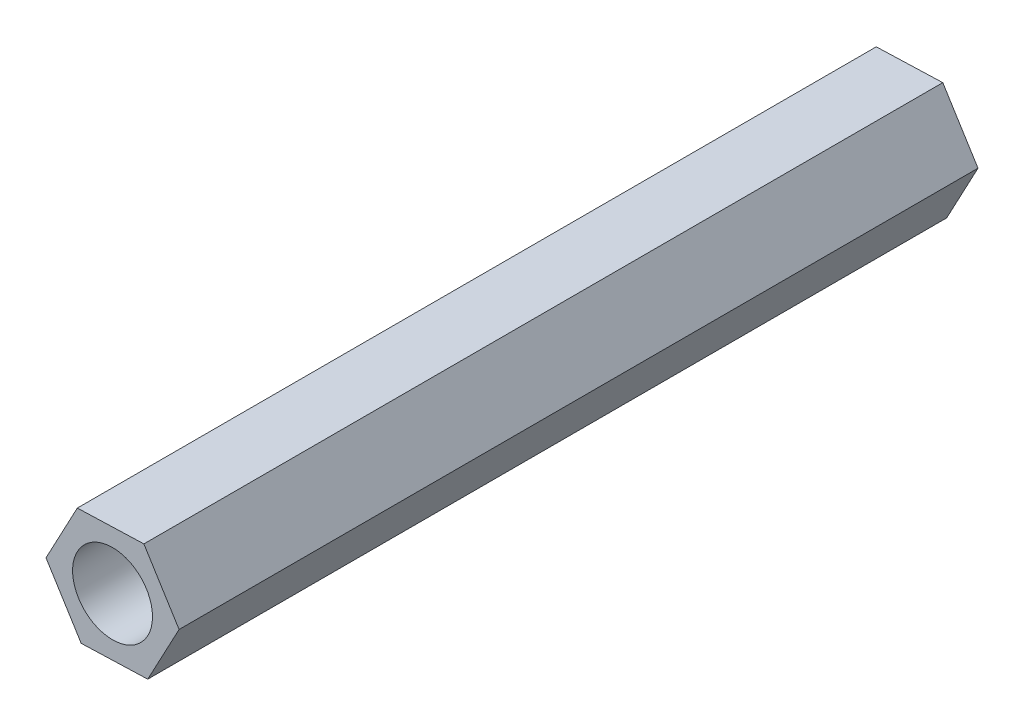
from build123d import *

# Parameters (mm, degrees)
SKETCH1_R           = 3
BOSS_EXTRUDE1_DEPTH = 60


with BuildPart() as part:
    # Sketch1 → Boss-Extrude1 (new body)
    with BuildSketch(Plane.XY):
        Polygon((2.64373815, -4.243895451), (4.997190346, 0.167596673), (2.353452196, 4.411492124), (-2.64373815, 4.243895451), (-4.997190346, -0.167596673), (-2.353452196, -4.411492124), align=None)
        Circle(SKETCH1_R, mode=Mode.SUBTRACT)
    extrude(amount=BOSS_EXTRUDE1_DEPTH)


solid = part.part
